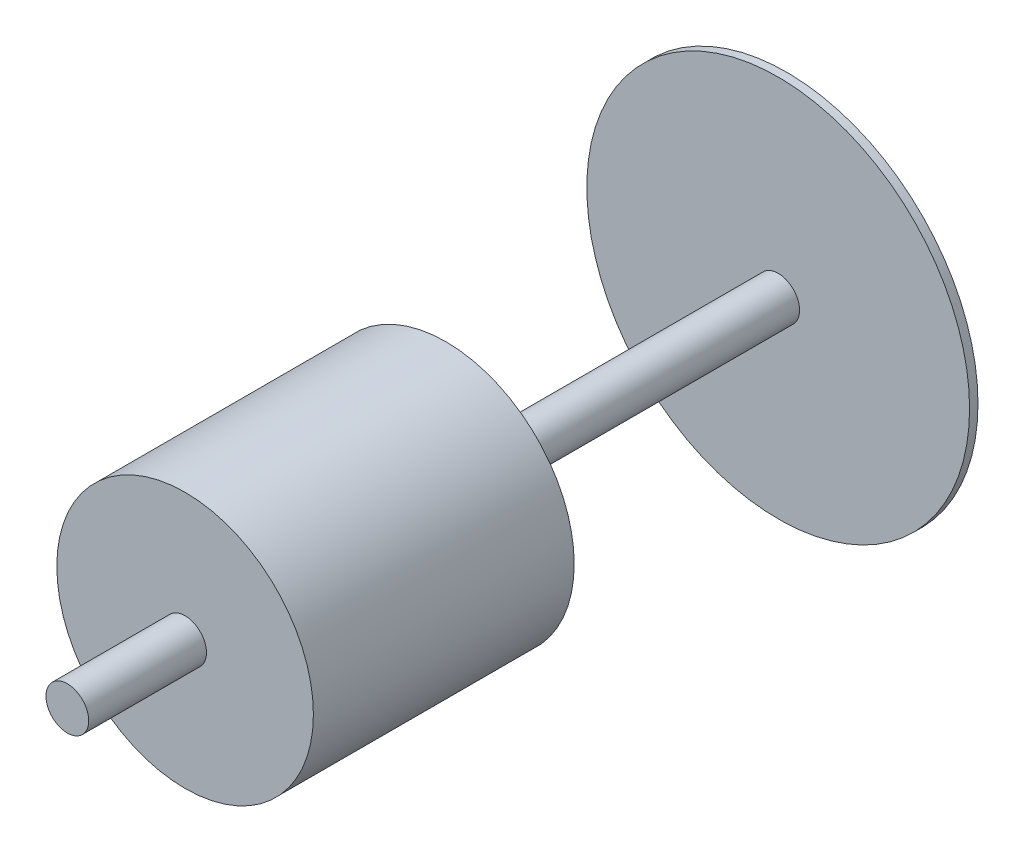
from build123d import *

# Parameters (mm, degrees)
SKETCH1_R                = 50.8
BOSS_EXTRUDE1_DEPTH      = 1030
BOSS_EXTRUDE1_DEPTH_BACK = 680
SKETCH2_R                = 455
BOSS_EXTRUDE2_DEPTH      = 20
BOSS_EXTRUDE3_START      = -280
SKETCH7_R                = 305
BOSS_EXTRUDE3_DEPTH      = 620
SKETCH8_R                = 225
BOSS_EXTRUDE4_DEPTH      = 50


with BuildPart() as part:
    # Sketch1 → Boss-Extrude1 (new body, two sides)
    with BuildSketch(Plane.XY) as boss_extrude1_sk:
        Circle(SKETCH1_R)
    extrude(amount=BOSS_EXTRUDE1_DEPTH)
    extrude(boss_extrude1_sk.sketch, amount=-BOSS_EXTRUDE1_DEPTH_BACK)

    # Sketch2 → Boss-Extrude2 (add)
    with BuildSketch(Plane.XY.offset(-680)):
        Circle(SKETCH2_R)
    extrude(amount=BOSS_EXTRUDE2_DEPTH)

    # Sketch7 → Boss-Extrude3 (add)
    with BuildSketch(Plane.XY.offset(1030).offset(BOSS_EXTRUDE3_START)):
        Circle(SKETCH7_R)
    extrude(amount=-BOSS_EXTRUDE3_DEPTH)

    # Sketch8 → Boss-Extrude4 (add)
    with BuildSketch(Plane(origin=(0, 0, 130), x_dir=(-1, 0, 0), z_dir=(0, 0, -1))):
        Circle(SKETCH8_R)
    extrude(amount=BOSS_EXTRUDE4_DEPTH)


solid = part.part
